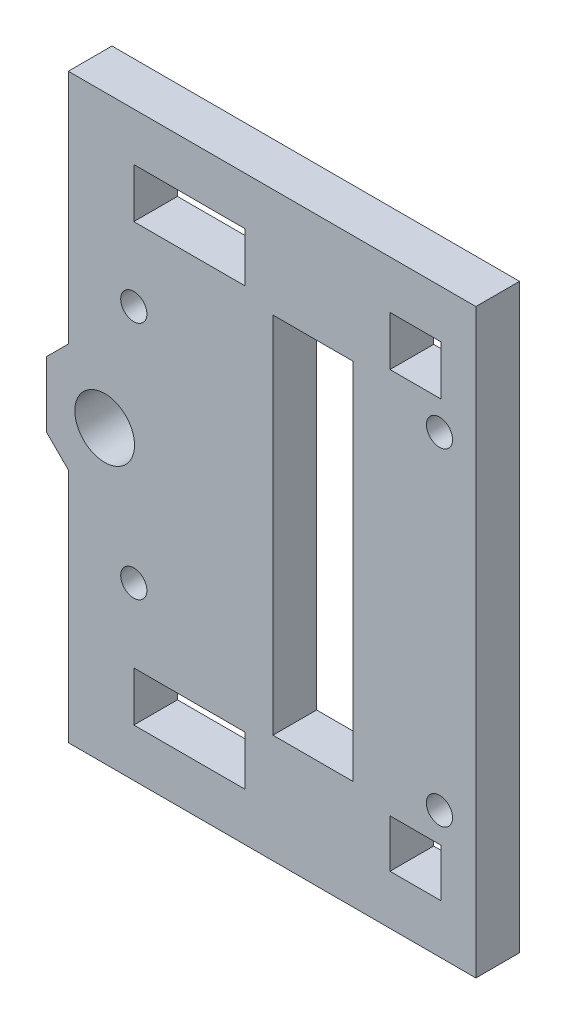
from build123d import *

# Parameters (mm, degrees)
MODEL_R                  = 1.8
MODEL_R_2                = 4.1
MODEL_W                  = 10.999995004
MODEL_H                  = 49.999979697
MODEL_W_2                = 7
MODEL_H_2                = 6.6
MODEL_W_3                = 15.312275424
MODEL_H_3                = 6.8
RESSALTO_EXTRUS_O1_DEPTH = 6


with BuildPart() as part:
    # Model → Ressalto-extrusão1 (new body)
    with BuildSketch(Plane.XY):
        Polygon((30.677261567, 6.624591957), (30.677261567, 39.085505862), (27.677261567, 42.085505862), (27.677261567, 51.063678051), (30.677261567, 54.063678051), (30.677261567, 86.524591957), (86.677261567, 86.524591957), (86.677261567, 6.624591957), align=None)
        with Locations((81.677261567, 24.074591957)):
            Circle(MODEL_R, mode=Mode.SUBTRACT)
        with Locations((39.677261567, 30.124591957)):
            Circle(MODEL_R, mode=Mode.SUBTRACT)
        with Locations((35.677261567, 46.574591957)):
            Circle(MODEL_R_2, mode=Mode.SUBTRACT)
        with Locations((39.677261567, 63.024591957)):
            Circle(MODEL_R, mode=Mode.SUBTRACT)
        with Locations((81.677261567, 69.074591957)):
            Circle(MODEL_R, mode=Mode.SUBTRACT)
        with Locations((64.294725156, 46.574591957)):
            Rectangle(MODEL_W, MODEL_H, mode=Mode.SUBTRACT)
        with Locations((78.377261567, 16.724591957)):
            Rectangle(MODEL_W_2, MODEL_H_2, mode=Mode.SUBTRACT)
        with Locations((47.333399279, 16.624591957)):
            Rectangle(MODEL_W_3, MODEL_H_3, mode=Mode.SUBTRACT)
        with Locations((47.333399279, 76.524591957)):
            Rectangle(MODEL_W_3, MODEL_H_3, mode=Mode.SUBTRACT)
        with Locations((78.377261567, 76.524591957)):
            Rectangle(MODEL_W_2, MODEL_H_3, mode=Mode.SUBTRACT)
    extrude(amount=RESSALTO_EXTRUS_O1_DEPTH)


solid = part.part
